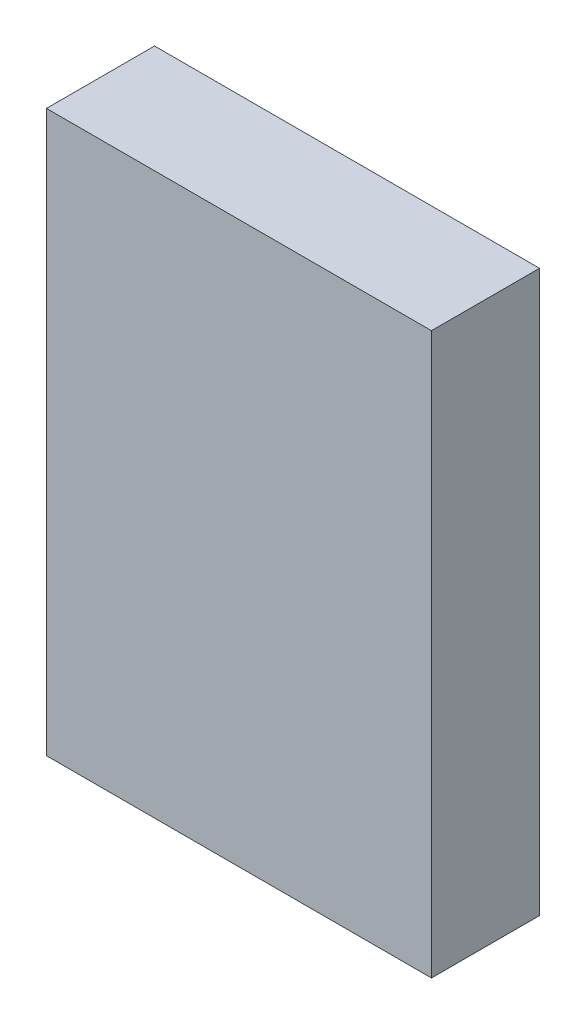
from build123d import *

# Parameters (mm, degrees)
SKETCH1_W           = 83
SKETCH1_H           = 57
BOSS_EXTRUDE1_DEPTH = 16


with BuildPart() as part:
    # Sketch1 → Boss-Extrude1 (new body)
    with BuildSketch(Plane(origin=(0, 0, 0), x_dir=(0, 1, 0), z_dir=(0, 0, 1))):
        with Locations((41.5, 28.5)):
            Rectangle(SKETCH1_W, SKETCH1_H)
    extrude(amount=BOSS_EXTRUDE1_DEPTH)


solid = part.part
